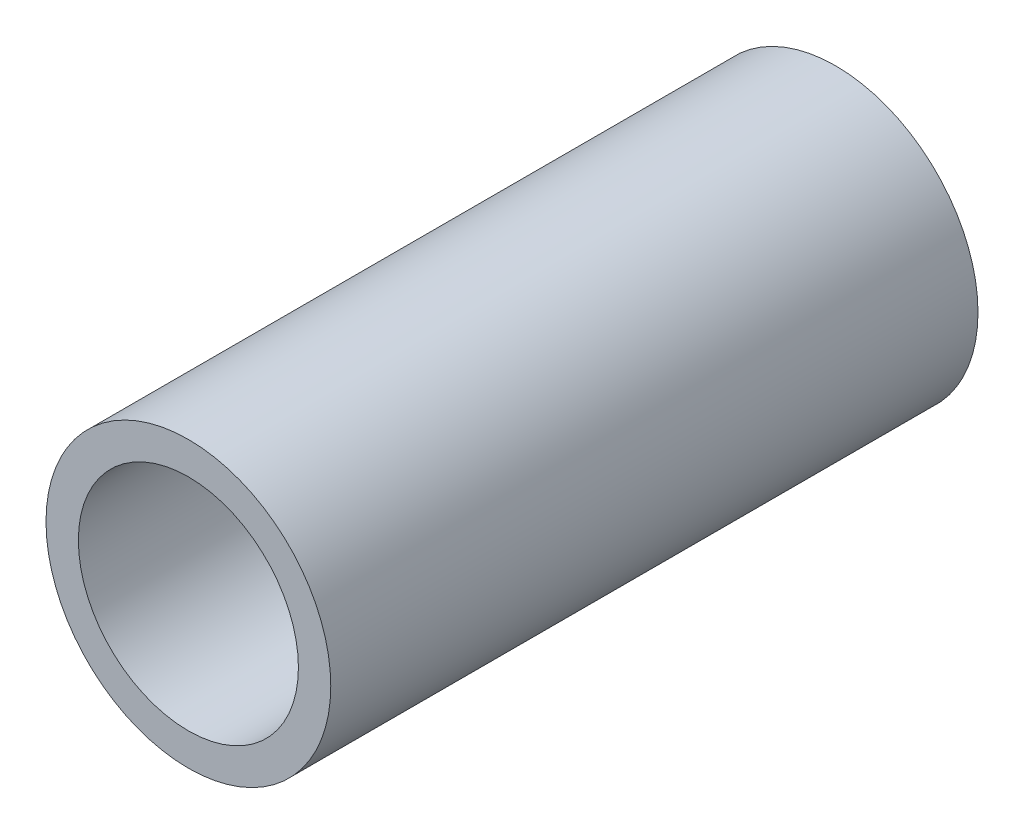
from build123d import *

# Parameters (mm, degrees)
CROQUIS1_R              = 2.2
CROQUIS1_R_2            = 1.7
SALIENTE_EXTRUIR1_DEPTH = 10


with BuildPart() as part:
    # Croquis1 → Saliente-Extruir1 (new body)
    with BuildSketch(Plane.XY):
        Circle(CROQUIS1_R)
        Circle(CROQUIS1_R_2, mode=Mode.SUBTRACT)
    extrude(amount=SALIENTE_EXTRUIR1_DEPTH)


solid = part.part
